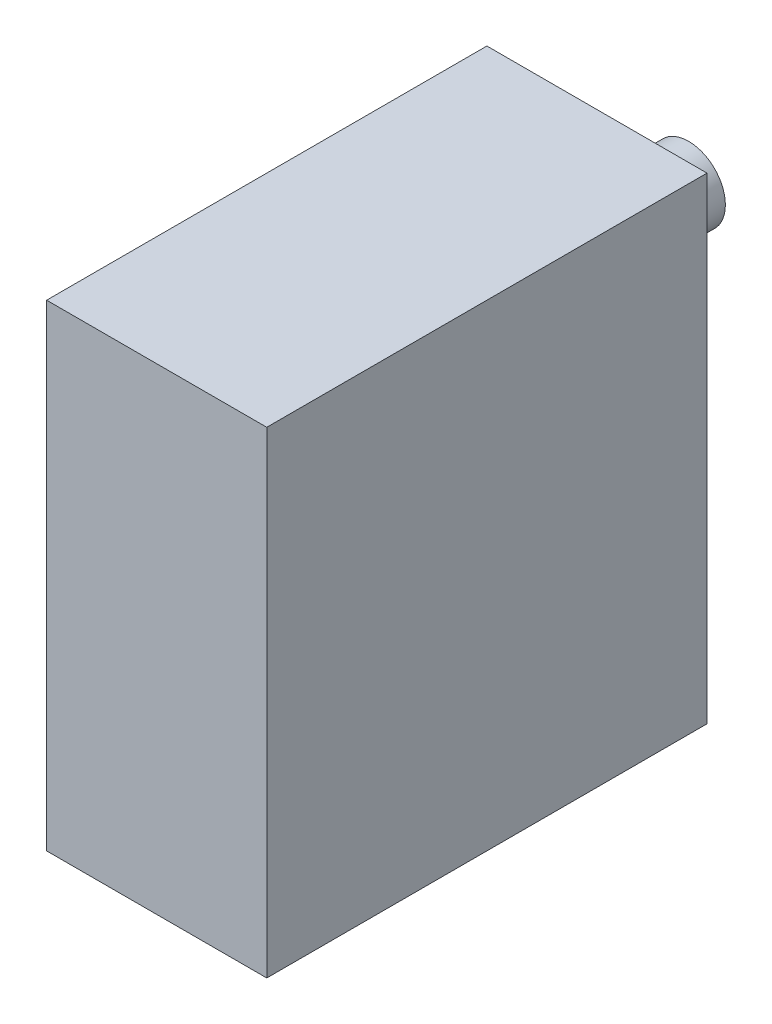
from build123d import *

# Parameters (mm, degrees)
SKETCH1_W           = 19.05
SKETCH1_H           = 41.275
BOSS_EXTRUDE1_DEPTH = 38.1
SKETCH6_R           = 3.175
BOSS_EXTRUDE4_DEPTH = 7.9375


with BuildPart() as part:
    # Sketch1 → Boss-Extrude1 (new body)
    with BuildSketch(Plane.XY):
        Rectangle(SKETCH1_W, SKETCH1_H)
    extrude(amount=BOSS_EXTRUDE1_DEPTH)

    # Sketch6 → Boss-Extrude4 (add)
    with BuildSketch(Plane(origin=(0, 0, 0), x_dir=(-1, 0, 0), z_dir=(0, 0, -1))):
        with Locations((0, 11.1125)):
            Circle(SKETCH6_R)
    extrude(amount=BOSS_EXTRUDE4_DEPTH)


solid = part.part
